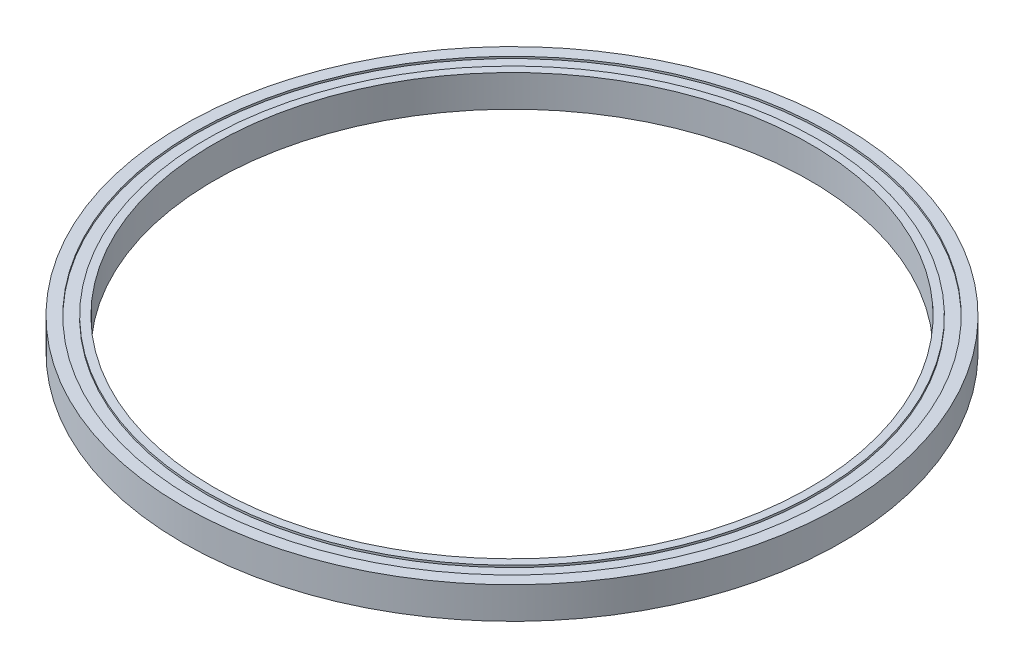
from build123d import *

# Parameters (mm, degrees)
SKETCH_1_R          = 83
SKETCH_1_R_2        = 75
EXTRUDE_1_DEPTH     = 8
SKETCH_2_R          = 80
SKETCH_2_R_2        = 77
CUT_EXTRUDE_1_DEPTH = 0.5
SKETCH_3_R          = 79.5
SKETCH_3_R_2        = 77
CUT_EXTRUDE_2_DEPTH = 0.5


with BuildPart() as part:
    # 草图1 → 凸台-拉伸1 (new body)
    with BuildSketch(Plane(origin=(0, 0, 0), x_dir=(1, 0, 0), z_dir=(0, 1, 0))):
        Circle(SKETCH_1_R)
        Circle(SKETCH_1_R_2, mode=Mode.SUBTRACT)
    extrude(amount=EXTRUDE_1_DEPTH)

    # 草图2 → 切除-拉伸1 (cut)
    with BuildSketch(Plane(origin=(0, 8, 0), x_dir=(1, 0, 0), z_dir=(0, 1, 0))):
        Circle(SKETCH_2_R)
        Circle(SKETCH_2_R_2, mode=Mode.SUBTRACT)
    extrude(amount=-CUT_EXTRUDE_1_DEPTH, mode=Mode.SUBTRACT)

    # 草图3 → 切除-拉伸2 (cut)
    with BuildSketch(Plane.XZ):
        Circle(SKETCH_3_R)
        Circle(SKETCH_3_R_2, mode=Mode.SUBTRACT)
    extrude(amount=-CUT_EXTRUDE_2_DEPTH, mode=Mode.SUBTRACT)


solid = part.part
